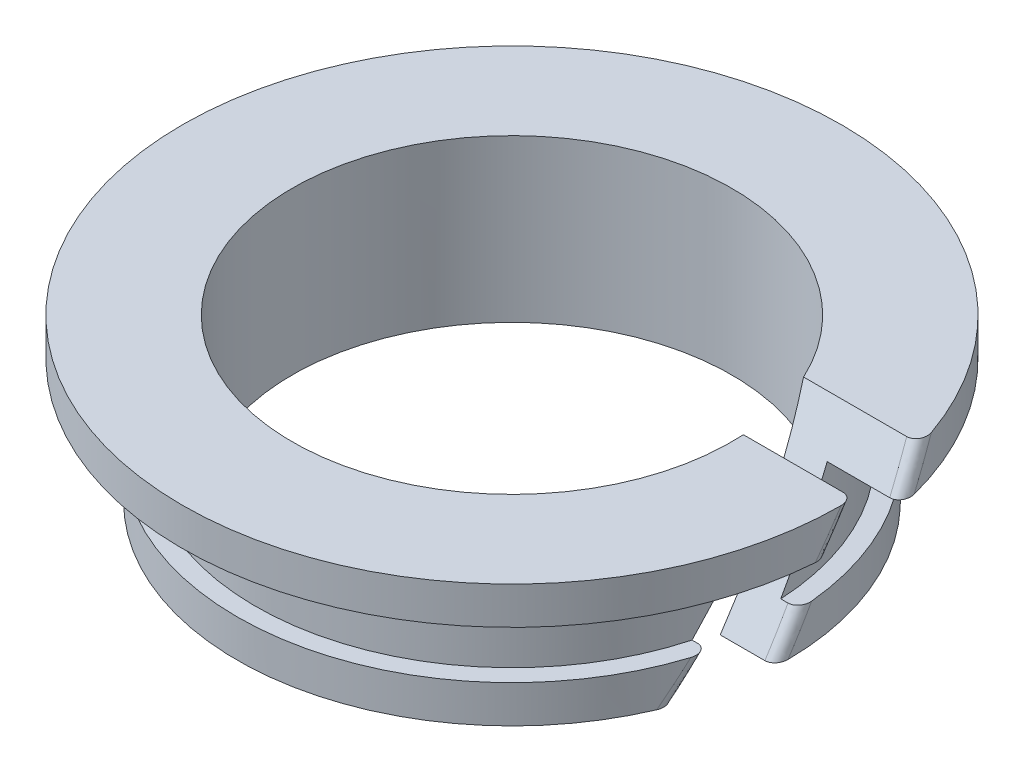
from build123d import *

# Parameters (mm, degrees)
CUT_EXTRUDE1_DEPTH = 8.14375
FILLET1_R          = 0.2286


with BuildPart() as part:
    # Sketch1 → Revolve1 (revolve)
    with BuildSketch(Plane.XY):
        Polygon((4.7625, 0), (5.953125, 0), (5.953125, 0.8128), (5.55625, 0.8128), (5.55625, 2.6924), (7.14375, 2.6924), (7.14375, 3.5052), (4.7625, 3.5052), align=None)
    revolve(axis=Axis((0, 18.790103573, 0), (0, -1, 0)))

    # Sketch2 → Cut-Extrude1 (cut, through all)
    with BuildSketch(Plane(origin=(0, 0, 0), x_dir=(0, 0, -1), z_dir=(1, 0, 0))):
        Polygon((1.996034078, 3.5052), (0.261163337, 3.5052), (-1.977379553, 0), (-0.242508813, 0), align=None)
    extrude(amount=CUT_EXTRUDE1_DEPTH, mode=Mode.SUBTRACT)

    # Fillet1
    fillet1_edges = [part.edges().sort_by_distance(p)[0] for p in [
        (5.699722818, 0.405539452, 1.718387925),
        (7.142556324, 3.300739905, -0.130587994),
        (5.95151838, 0.596281949, -0.138297622),
        (6.929392139, 3.099377561, -1.736861724),
    ]]
    fillet(fillet1_edges, radius=FILLET1_R)


solid = part.part
